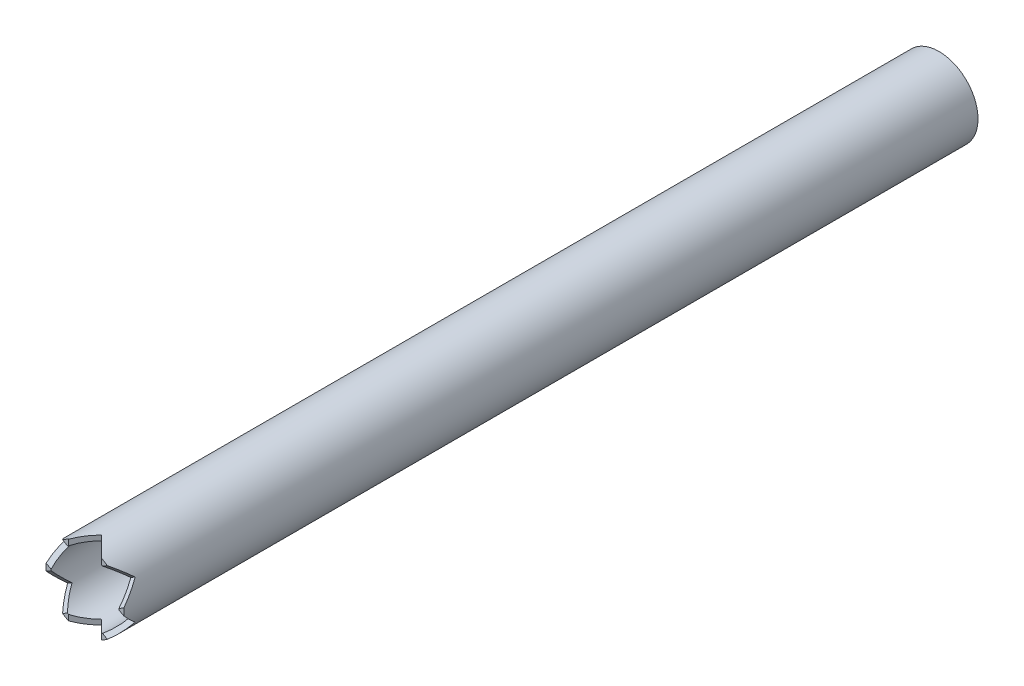
from build123d import *

# Parameters (mm, degrees)
SKETCH12_R                   = 30.1625
SKETCH12_R_2                 = 26.2509
PIPE_STANDARD_S40_P2_1_DEPTH = 660.4
CUT_EXTRUDE1_DEPTH           = 662.7761803
CUT_EXTRUDE1_DEPTH_BACK      = 662.7761803
CUT_EXTRUDE2_DEPTH           = 662.7761803
CUT_EXTRUDE2_DEPTH_BACK      = 662.7761803
CUT_EXTRUDE3_DEPTH           = 662.7761803
CUT_EXTRUDE3_DEPTH_BACK      = 662.7761803


with BuildPart() as part:
    # Sketch12 → Pipe (standard, s40) P2(1) (new body)
    with BuildSketch(Plane(origin=(0, 0, 0), x_dir=(-1, 0, 0), z_dir=(0, 0, -1))):
        Circle(SKETCH12_R)
        Circle(SKETCH12_R_2, mode=Mode.SUBTRACT)
    extrude(amount=PIPE_STANDARD_S40_P2_1_DEPTH)

    # Sketch14 → Cut-Extrude1 (cut, two sides)
    with BuildSketch(Plane(origin=(0, 0, 0), x_dir=(1, 0, 0), z_dir=(0, 1, 0))) as cut_extrude1_sk:
        Polygon((0, 12.7), (-12.7, 0), (12.7, 0), align=None)
    extrude(amount=CUT_EXTRUDE1_DEPTH, mode=Mode.SUBTRACT)
    extrude(cut_extrude1_sk.sketch, amount=-CUT_EXTRUDE1_DEPTH_BACK, mode=Mode.SUBTRACT)

    # Sketch15 → Cut-Extrude2 (cut, two sides)
    with BuildSketch(Plane(origin=(0, 0, 0), x_dir=(0, 0, -1), z_dir=(0.8660254037844364, -0.5000000000000041, 0))) as cut_extrude2_sk:
        Polygon((0, 12.7), (0, -12.7), (12.7, 0), align=None)
    extrude(amount=CUT_EXTRUDE2_DEPTH, mode=Mode.SUBTRACT)
    extrude(cut_extrude2_sk.sketch, amount=-CUT_EXTRUDE2_DEPTH_BACK, mode=Mode.SUBTRACT)

    # Sketch16 → Cut-Extrude3 (cut, two sides)
    with BuildSketch(Plane(origin=(0, 0, 0), x_dir=(0, 0, -1), z_dir=(-0.8660254037844433, -0.49999999999999195, 0))) as cut_extrude3_sk:
        Polygon((0, 12.7), (0, -12.7), (12.7, 0), align=None)
    extrude(amount=CUT_EXTRUDE3_DEPTH, mode=Mode.SUBTRACT)
    extrude(cut_extrude3_sk.sketch, amount=-CUT_EXTRUDE3_DEPTH_BACK, mode=Mode.SUBTRACT)


solid = part.part
